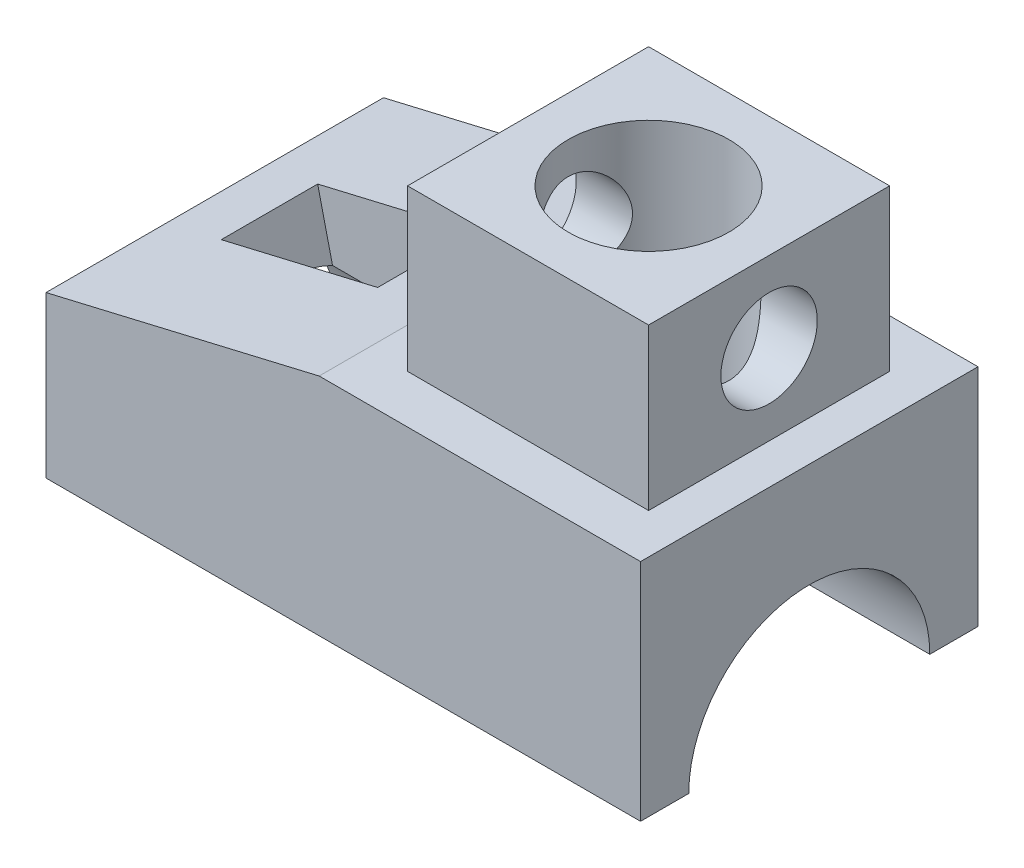
from build123d import *

# Parameters (mm, degrees)
BOSS_EXTRUDE1_DEPTH = 42
SKETCH2_R           = 15
CUT_EXTRUDE1_DEPTH  = 74
SKETCH3_W           = 20
SKETCH3_H           = 12
CUT_EXTRUDE4_DEPTH  = 74
SKETCH4_W           = 30
SKETCH4_H           = 30
BOSS_EXTRUDE2_DEPTH = 20
SKETCH5_R           = 6
CUT_EXTRUDE5_DEPTH  = 30
SKETCH6_R           = 10
CUT_EXTRUDE6_DEPTH  = 40


with BuildPart() as part:
    # Sketch1 → Boss-Extrude1 (new body)
    with BuildSketch(Plane.XY):
        Polygon((0, 0), (74, 0), (74, 28), (34, 28), (0, 20), align=None)
    extrude(amount=-BOSS_EXTRUDE1_DEPTH)

    # Sketch2 → Cut-Extrude1 (cut)
    with BuildSketch(Plane.ZY):
        with Locations((-21, 0)):
            Circle(SKETCH2_R)
    extrude(amount=-CUT_EXTRUDE1_DEPTH, mode=Mode.SUBTRACT)

    # Sketch3 → Cut-Extrude4 (cut)
    with BuildSketch(Plane(origin=(-4.459016393, 18.950819672, 0), x_dir=(0.973417168, 0.229039334, 0), z_dir=(-0.229039334, 0.973417168, 0))):
        with Locations((21.580786675, 21)):
            Rectangle(SKETCH3_W, SKETCH3_H)
    extrude(amount=-CUT_EXTRUDE4_DEPTH, mode=Mode.SUBTRACT)

    # Sketch4 → Boss-Extrude2 (add)
    with BuildSketch(Plane(origin=(0, 28, 0), x_dir=(1, 0, 0), z_dir=(0, 1, 0))):
        with Locations((54, 21)):
            Rectangle(SKETCH4_W, SKETCH4_H)
    extrude(amount=BOSS_EXTRUDE2_DEPTH)

    # Sketch5 → Cut-Extrude5 (cut)
    with BuildSketch(Plane.ZY.offset(-39)):
        with Locations((-21, 38)):
            Circle(SKETCH5_R)
    extrude(amount=-CUT_EXTRUDE5_DEPTH, mode=Mode.SUBTRACT)

    # Sketch6 → Cut-Extrude6 (cut)
    with BuildSketch(Plane(origin=(0, 48, 0), x_dir=(1, 0, 0), z_dir=(0, 1, 0))):
        with Locations((54, 21)):
            Circle(SKETCH6_R)
    extrude(amount=-CUT_EXTRUDE6_DEPTH, mode=Mode.SUBTRACT)


solid = part.part
